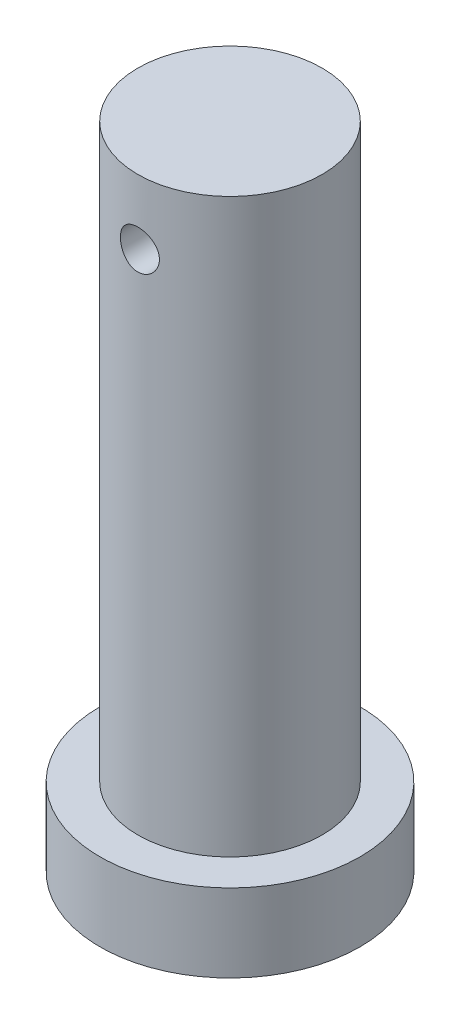
from build123d import *

# Parameters (mm, degrees)
SKETCH3_R               = 3.75
CUT_EXTRUDE1_DEPTH      = 26
CUT_EXTRUDE1_DEPTH_BACK = 26


with BuildPart() as part:
    # Sketch2 → Revolve1 (revolve)
    with BuildSketch(Plane.XY):
        Polygon((0, 0), (25, 0), (25, 15), (17.7222, 15), (17.7222, 125), (0, 125), align=None)
    revolve(axis=Axis((0, 125, 0), (0, -1, 0)))

    # Sketch3 → Cut-Extrude1 (cut, two sides)
    with BuildSketch(Plane.XY) as cut_extrude1_sk:
        with Locations((0, 112.5)):
            Circle(SKETCH3_R)
    extrude(amount=CUT_EXTRUDE1_DEPTH, mode=Mode.SUBTRACT)
    extrude(cut_extrude1_sk.sketch, amount=-CUT_EXTRUDE1_DEPTH_BACK, mode=Mode.SUBTRACT)


solid = part.part
